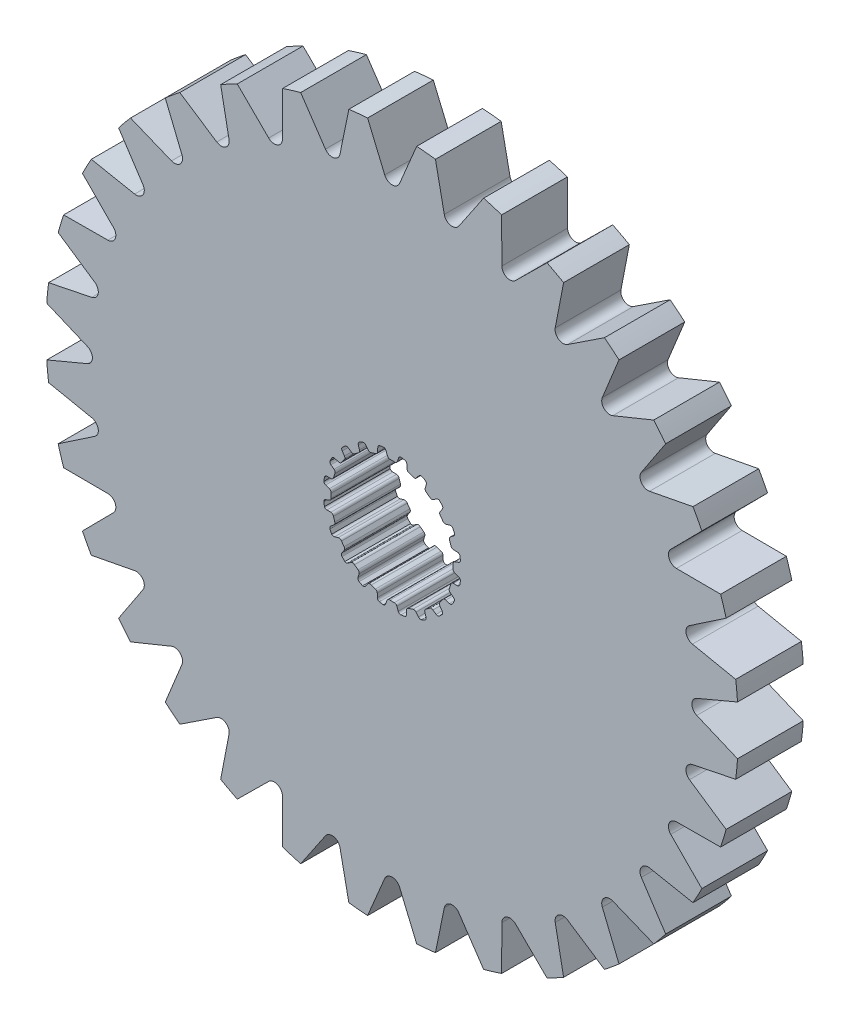
from build123d import *

# Parameters (mm, degrees)
SKETCH1_R           = 16.860601328
BOSS_EXTRUDE1_DEPTH = 1.6002
CUT_EXTRUDE1_DEPTH  = 3.2004


with BuildPart() as part:
    # Sketch1 → Boss-Extrude1 (new body, symmetric)
    with BuildSketch(Plane.XY):
        Circle(SKETCH1_R)
        with BuildLine():
            Line((-0.106949245, 2.969874934), (0.106949245, 2.969874934))
            ThreePointArc((0.106949245, 2.969874934), (0.196343213, 2.986924176), (0.253739238, 3.057547504))
            Line((0.253739238, 3.057547504), (0.315888147, 3.237526941))
            ThreePointArc((0.315888147, 3.237526941), (0.359032156, 3.298322911), (0.4281449, 3.326269005))
            Line((0.4281449, 3.326269005), (0.620027588, 3.2937547))
            ThreePointArc((0.620027588, 3.2937547), (0.689621142, 3.24802576), (0.718272212, 3.169836791))
            Line((0.718272212, 3.169836791), (0.724389167, 2.979527391))
            ThreePointArc((0.724389167, 2.979527391), (0.750934762, 2.9040661), (0.816027049, 2.857568043))
            Line((0.816027049, 2.857568043), (1.019456602, 2.791469774))
            ThreePointArc((1.019456602, 2.791469774), (1.109743823, 2.780060312), (1.186154496, 2.829490741))
            Line((1.186154496, 2.829490741), (1.300878326, 2.981456288))
            ThreePointArc((1.300878326, 2.981456288), (1.360697704, 3.02594446), (1.435063648, 3.031165762))
            Line((1.435063648, 3.031165762), (1.607507455, 2.940947809))
            ThreePointArc((1.607507455, 2.940947809), (1.659563839, 2.875951412), (1.662650905, 2.792735615))
            Line((1.662650905, 2.792735615), (1.609659636, 2.609850378))
            ThreePointArc((1.609659636, 2.609850378), (1.611587176, 2.529879385), (1.659124931, 2.465542482))
            Line((1.659124931, 2.465542482), (1.832172444, 2.339816104))
            ThreePointArc((1.832172444, 2.339816104), (1.914514976, 2.301064775), (2.002460687, 2.32446371))
            Line((2.002460687, 2.32446371), (2.158529469, 2.433539921))
            ThreePointArc((2.158529469, 2.433539921), (2.229168681, 2.457365482), (2.301508367, 2.439350895))
            Line((2.301508367, 2.439350895), (2.437633293, 2.300260456))
            ThreePointArc((2.437633293, 2.300260456), (2.467056864, 2.222358901), (2.444277744, 2.14226202))
            Line((2.444277744, 2.14226202), (2.337365406, 1.984703026))
            ThreePointArc((2.337365406, 1.984703026), (2.314486209, 1.908050449), (2.339816104, 1.832172444))
            Line((2.339816104, 1.832172444), (2.465542482, 1.659124931))
            ThreePointArc((2.465542482, 1.659124931), (2.531880064, 1.596824985), (2.622752074, 1.591901975))
            Line((2.622752074, 1.591901975), (2.804888709, 1.64741171))
            ThreePointArc((2.804888709, 1.64741171), (2.879433095, 1.648242449), (2.942665411, 1.608755366))
            Line((2.942665411, 1.608755366), (3.0291466, 1.434407582))
            ThreePointArc((3.0291466, 1.434407582), (3.033057175, 1.351226417), (2.986641646, 1.282088892))
            Line((2.986641646, 1.282088892), (2.836273564, 1.165279113))
            ThreePointArc((2.836273564, 1.165279113), (2.790827206, 1.099448241), (2.791469774, 1.019456602))
            Line((2.791469774, 1.019456602), (2.857568043, 0.816027049))
            ThreePointArc((2.857568043, 0.816027049), (2.901407091, 0.736276839), (2.986310214, 0.703513784))
            Line((2.986310214, 0.703513784), (3.1766859, 0.700023363))
            ThreePointArc((3.1766859, 0.700023363), (3.247838536, 0.677777961), (3.295773863, 0.620683653))
            Line((3.295773863, 0.620683653), (3.324145932, 0.4281449))
            ThreePointArc((3.324145932, 0.4281449), (3.302160717, 0.347826477), (3.236652255, 0.29641597))
            Line((3.236652255, 0.29641597), (3.057547504, 0.231789562))
            ThreePointArc((3.057547504, 0.231789562), (2.993982591, 0.183224379), (2.969874934, 0.106949245))
            Line((2.969874934, 0.106949245), (2.969874934, -0.106949245))
            ThreePointArc((2.969874934, -0.106949245), (2.986924176, -0.196343213), (3.057547504, -0.253739238))
            Line((3.057547504, -0.253739238), (3.237526941, -0.315888147))
            ThreePointArc((3.237526941, -0.315888147), (3.298322911, -0.359032156), (3.326269005, -0.4281449))
            Line((3.326269005, -0.4281449), (3.2937547, -0.620027588))
            ThreePointArc((3.2937547, -0.620027588), (3.24802576, -0.689621142), (3.169836791, -0.718272212))
            Line((3.169836791, -0.718272212), (2.979527391, -0.724389167))
            ThreePointArc((2.979527391, -0.724389167), (2.9040661, -0.750934762), (2.857568043, -0.816027049))
            Line((2.857568043, -0.816027049), (2.791469774, -1.019456602))
            ThreePointArc((2.791469774, -1.019456602), (2.780060312, -1.109743823), (2.829490741, -1.186154496))
            Line((2.829490741, -1.186154496), (2.981456288, -1.300878326))
            ThreePointArc((2.981456288, -1.300878326), (3.02594446, -1.360697704), (3.031165762, -1.435063648))
            Line((3.031165762, -1.435063648), (2.940947809, -1.607507455))
            ThreePointArc((2.940947809, -1.607507455), (2.875951412, -1.659563839), (2.792735615, -1.662650905))
            Line((2.792735615, -1.662650905), (2.609850378, -1.609659636))
            ThreePointArc((2.609850378, -1.609659636), (2.529879385, -1.611587176), (2.465542482, -1.659124931))
            Line((2.465542482, -1.659124931), (2.339816104, -1.832172444))
            ThreePointArc((2.339816104, -1.832172444), (2.301064775, -1.914514976), (2.32446371, -2.002460687))
            Line((2.32446371, -2.002460687), (2.433539921, -2.158529469))
            ThreePointArc((2.433539921, -2.158529469), (2.457365482, -2.229168681), (2.439350895, -2.301508367))
            Line((2.439350895, -2.301508367), (2.300260456, -2.437633293))
            ThreePointArc((2.300260456, -2.437633293), (2.222358901, -2.467056864), (2.14226202, -2.444277744))
            Line((2.14226202, -2.444277744), (1.984703026, -2.337365406))
            ThreePointArc((1.984703026, -2.337365406), (1.908050449, -2.314486209), (1.832172444, -2.339816104))
            Line((1.832172444, -2.339816104), (1.659124931, -2.465542482))
            ThreePointArc((1.659124931, -2.465542482), (1.596824985, -2.531880064), (1.591901975, -2.622752074))
            Line((1.591901975, -2.622752074), (1.64741171, -2.804888709))
            ThreePointArc((1.64741171, -2.804888709), (1.648242449, -2.879433095), (1.608755366, -2.942665411))
            Line((1.608755366, -2.942665411), (1.434407582, -3.0291466))
            ThreePointArc((1.434407582, -3.0291466), (1.351226417, -3.033057175), (1.282088892, -2.986641646))
            Line((1.282088892, -2.986641646), (1.165279113, -2.836273564))
            ThreePointArc((1.165279113, -2.836273564), (1.099448241, -2.790827206), (1.019456602, -2.791469774))
            Line((1.019456602, -2.791469774), (0.816027049, -2.857568043))
            ThreePointArc((0.816027049, -2.857568043), (0.736276839, -2.901407091), (0.703513784, -2.986310214))
            Line((0.703513784, -2.986310214), (0.700023363, -3.1766859))
            ThreePointArc((0.700023363, -3.1766859), (0.677777961, -3.247838536), (0.620683653, -3.295773863))
            Line((0.620683653, -3.295773863), (0.4281449, -3.324145932))
            ThreePointArc((0.4281449, -3.324145932), (0.347826477, -3.302160717), (0.29641597, -3.236652255))
            Line((0.29641597, -3.236652255), (0.231789562, -3.057547504))
            ThreePointArc((0.231789562, -3.057547504), (0.183224379, -2.993982591), (0.106949245, -2.969874934))
            Line((0.106949245, -2.969874934), (-0.106949245, -2.969874934))
            ThreePointArc((-0.106949245, -2.969874934), (-0.196343213, -2.986924176), (-0.253739238, -3.057547504))
            Line((-0.253739238, -3.057547504), (-0.315888147, -3.237526941))
            ThreePointArc((-0.315888147, -3.237526941), (-0.359032156, -3.298322911), (-0.4281449, -3.326269005))
            Line((-0.4281449, -3.326269005), (-0.620027588, -3.2937547))
            ThreePointArc((-0.620027588, -3.2937547), (-0.689621142, -3.24802576), (-0.718272212, -3.169836791))
            Line((-0.718272212, -3.169836791), (-0.724389167, -2.979527391))
            ThreePointArc((-0.724389167, -2.979527391), (-0.750934762, -2.9040661), (-0.816027049, -2.857568043))
            Line((-0.816027049, -2.857568043), (-1.019456602, -2.791469774))
            ThreePointArc((-1.019456602, -2.791469774), (-1.109743823, -2.780060312), (-1.186154496, -2.829490741))
            Line((-1.186154496, -2.829490741), (-1.300878326, -2.981456288))
            ThreePointArc((-1.300878326, -2.981456288), (-1.360697704, -3.02594446), (-1.435063648, -3.031165762))
            Line((-1.435063648, -3.031165762), (-1.607507455, -2.940947809))
            ThreePointArc((-1.607507455, -2.940947809), (-1.659563839, -2.875951412), (-1.662650905, -2.792735615))
            Line((-1.662650905, -2.792735615), (-1.609659636, -2.609850378))
            ThreePointArc((-1.609659636, -2.609850378), (-1.611587176, -2.529879385), (-1.659124931, -2.465542482))
            Line((-1.659124931, -2.465542482), (-1.832172444, -2.339816104))
            ThreePointArc((-1.832172444, -2.339816104), (-1.914514976, -2.301064775), (-2.002460687, -2.32446371))
            Line((-2.002460687, -2.32446371), (-2.158529469, -2.433539921))
            ThreePointArc((-2.158529469, -2.433539921), (-2.229168681, -2.457365482), (-2.301508367, -2.439350895))
            Line((-2.301508367, -2.439350895), (-2.437633293, -2.300260456))
            ThreePointArc((-2.437633293, -2.300260456), (-2.467056864, -2.222358901), (-2.444277744, -2.14226202))
            Line((-2.444277744, -2.14226202), (-2.337365406, -1.984703026))
            ThreePointArc((-2.337365406, -1.984703026), (-2.314486209, -1.908050449), (-2.339816104, -1.832172444))
            Line((-2.339816104, -1.832172444), (-2.465542482, -1.659124931))
            ThreePointArc((-2.465542482, -1.659124931), (-2.531880064, -1.596824985), (-2.622752074, -1.591901975))
            Line((-2.622752074, -1.591901975), (-2.804888709, -1.64741171))
            ThreePointArc((-2.804888709, -1.64741171), (-2.879433095, -1.648242449), (-2.942665411, -1.608755366))
            Line((-2.942665411, -1.608755366), (-3.0291466, -1.434407582))
            ThreePointArc((-3.0291466, -1.434407582), (-3.033057175, -1.351226417), (-2.986641646, -1.282088892))
            Line((-2.986641646, -1.282088892), (-2.836273564, -1.165279113))
            ThreePointArc((-2.836273564, -1.165279113), (-2.790827206, -1.099448241), (-2.791469774, -1.019456602))
            Line((-2.791469774, -1.019456602), (-2.857568043, -0.816027049))
            ThreePointArc((-2.857568043, -0.816027049), (-2.901407091, -0.736276839), (-2.986310214, -0.703513784))
            Line((-2.986310214, -0.703513784), (-3.1766859, -0.700023363))
            ThreePointArc((-3.1766859, -0.700023363), (-3.247838536, -0.677777961), (-3.295773863, -0.620683653))
            Line((-3.295773863, -0.620683653), (-3.324145932, -0.4281449))
            ThreePointArc((-3.324145932, -0.4281449), (-3.302160717, -0.347826477), (-3.236652255, -0.29641597))
            Line((-3.236652255, -0.29641597), (-3.057547504, -0.231789562))
            ThreePointArc((-3.057547504, -0.231789562), (-2.993982591, -0.183224379), (-2.969874934, -0.106949245))
            Line((-2.969874934, -0.106949245), (-2.969874934, 0.106949245))
            ThreePointArc((-2.969874934, 0.106949245), (-2.986924176, 0.196343213), (-3.057547504, 0.253739238))
            Line((-3.057547504, 0.253739238), (-3.237526941, 0.315888147))
            ThreePointArc((-3.237526941, 0.315888147), (-3.298322911, 0.359032156), (-3.326269005, 0.4281449))
            Line((-3.326269005, 0.4281449), (-3.2937547, 0.620027588))
            ThreePointArc((-3.2937547, 0.620027588), (-3.24802576, 0.689621142), (-3.169836791, 0.718272212))
            Line((-3.169836791, 0.718272212), (-2.979527391, 0.724389167))
            ThreePointArc((-2.979527391, 0.724389167), (-2.9040661, 0.750934762), (-2.857568043, 0.816027049))
            Line((-2.857568043, 0.816027049), (-2.791469774, 1.019456602))
            ThreePointArc((-2.791469774, 1.019456602), (-2.780060312, 1.109743823), (-2.829490741, 1.186154496))
            Line((-2.829490741, 1.186154496), (-2.981456288, 1.300878326))
            ThreePointArc((-2.981456288, 1.300878326), (-3.02594446, 1.360697704), (-3.031165762, 1.435063648))
            Line((-3.031165762, 1.435063648), (-2.940947809, 1.607507455))
            ThreePointArc((-2.940947809, 1.607507455), (-2.875951412, 1.659563839), (-2.792735615, 1.662650905))
            Line((-2.792735615, 1.662650905), (-2.609850378, 1.609659636))
            ThreePointArc((-2.609850378, 1.609659636), (-2.529879385, 1.611587176), (-2.465542482, 1.659124931))
            Line((-2.465542482, 1.659124931), (-2.339816104, 1.832172444))
            ThreePointArc((-2.339816104, 1.832172444), (-2.301064775, 1.914514976), (-2.32446371, 2.002460687))
            Line((-2.32446371, 2.002460687), (-2.433539921, 2.158529469))
            ThreePointArc((-2.433539921, 2.158529469), (-2.457365482, 2.229168681), (-2.439350895, 2.301508367))
            Line((-2.439350895, 2.301508367), (-2.300260456, 2.437633293))
            ThreePointArc((-2.300260456, 2.437633293), (-2.222358901, 2.467056864), (-2.14226202, 2.444277744))
            Line((-2.14226202, 2.444277744), (-1.984703026, 2.337365406))
            ThreePointArc((-1.984703026, 2.337365406), (-1.908050449, 2.314486209), (-1.832172444, 2.339816104))
            Line((-1.832172444, 2.339816104), (-1.659124931, 2.465542482))
            ThreePointArc((-1.659124931, 2.465542482), (-1.596824985, 2.531880064), (-1.591901975, 2.622752074))
            Line((-1.591901975, 2.622752074), (-1.64741171, 2.804888709))
            ThreePointArc((-1.64741171, 2.804888709), (-1.648242449, 2.879433095), (-1.608755366, 2.942665411))
            Line((-1.608755366, 2.942665411), (-1.434407582, 3.0291466))
            ThreePointArc((-1.434407582, 3.0291466), (-1.351226417, 3.033057175), (-1.282088892, 2.986641646))
            Line((-1.282088892, 2.986641646), (-1.165279113, 2.836273564))
            ThreePointArc((-1.165279113, 2.836273564), (-1.099448241, 2.790827206), (-1.019456602, 2.791469774))
            Line((-1.019456602, 2.791469774), (-0.816027049, 2.857568043))
            ThreePointArc((-0.816027049, 2.857568043), (-0.736276839, 2.901407091), (-0.703513784, 2.986310214))
            Line((-0.703513784, 2.986310214), (-0.700023363, 3.1766859))
            ThreePointArc((-0.700023363, 3.1766859), (-0.677777961, 3.247838536), (-0.620683653, 3.295773863))
            Line((-0.620683653, 3.295773863), (-0.4281449, 3.324145932))
            ThreePointArc((-0.4281449, 3.324145932), (-0.347826477, 3.302160717), (-0.29641597, 3.236652255))
            Line((-0.29641597, 3.236652255), (-0.231789562, 3.057547504))
            ThreePointArc((-0.231789562, 3.057547504), (-0.183224379, 2.993982591), (-0.106949245, 2.969874934))
        make_face(mode=Mode.SUBTRACT)
    extrude(amount=BOSS_EXTRUDE1_DEPTH, both=True)

    # Sketch2 → Cut-Extrude1 (cut)
    with BuildSketch(Plane.XY.offset(1.6002)):
        with BuildLine():
            Line((-1.195753421, 16.818146476), (-0.361266579, 14.83454632))
            ThreePointArc((-0.361266579, 14.83454632), (0, 14.594594775), (0.361266579, 14.83454632))
            Line((0.361266579, 14.83454632), (1.195753421, 16.818146476))
            ThreePointArc((1.195753421, 16.818146476), (0, 16.860601328), (-1.195753421, 16.818146476))
        make_face()
        with BuildLine():
            Line((4.453834966, 16.261710587), (3.248401362, 14.479025059))
            ThreePointArc((3.248401362, 14.479025059), (2.847264194, 14.314163729), (2.539751475, 14.619984285))
            Line((2.539751475, 14.619984285), (2.108280258, 16.728270427))
            ThreePointArc((2.108280258, 16.728270427), (3.289340142, 16.536629601), (4.453834966, 16.261710587))
        make_face()
        with BuildLine():
            Line((7.540758131, 15.080346281), (6.010701902, 13.567082984))
            ThreePointArc((6.010701902, 13.567082984), (5.585109623, 13.483647398), (5.343168305, 13.843584454))
            Line((5.343168305, 13.843584454), (5.331293908, 15.995536327))
            ThreePointArc((5.331293908, 15.995536327), (6.452272788, 15.577164472), (7.540758131, 15.080346281))
        make_face()
        with BuildLine():
            Line((10.33789419, 13.319452723), (8.542014538, 12.133765519))
            ThreePointArc((8.542014538, 12.133765519), (8.10832242, 12.134962059), (7.941250173, 12.535183435))
            Line((7.941250173, 12.535183435), (8.349428924, 14.648102736))
            ThreePointArc((8.349428924, 14.648102736), (9.367248208, 14.019077649), (10.33789419, 13.319452723))
        make_face()
        with BuildLine():
            Line((12.737750772, 11.046700068), (10.745062347, 10.23415425))
            ThreePointArc((10.745062347, 10.23415425), (10.319936934, 10.319936934), (10.23415425, 10.745062347))
            Line((10.23415425, 10.745062347), (11.046700068, 12.737750772))
            ThreePointArc((11.046700068, 12.737750772), (11.922245534, 11.922245534), (12.737750772, 11.046700068))
        make_face()
        with BuildLine():
            Line((14.648102736, 8.349428924), (12.535183435, 7.941250173))
            ThreePointArc((12.535183435, 7.941250173), (12.134962059, 8.10832242), (12.133765519, 8.542014538))
            Line((12.133765519, 8.542014538), (13.319452723, 10.33789419))
            ThreePointArc((13.319452723, 10.33789419), (14.019077649, 9.367248208), (14.648102736, 8.349428924))
        make_face()
        with BuildLine():
            Line((15.995536327, 5.331293908), (13.843584454, 5.343168305))
            ThreePointArc((13.843584454, 5.343168305), (13.483647398, 5.585109623), (13.567082984, 6.010701902))
            Line((13.567082984, 6.010701902), (15.080346281, 7.540758131))
            ThreePointArc((15.080346281, 7.540758131), (15.577164472, 6.452272788), (15.995536327, 5.331293908))
        make_face()
        with BuildLine():
            Line((16.728270427, 2.108280258), (14.619984285, 2.539751475))
            ThreePointArc((14.619984285, 2.539751475), (14.314163729, 2.847264194), (14.479025059, 3.248401362))
            Line((14.479025059, 3.248401362), (16.261710587, 4.453834966))
            ThreePointArc((16.261710587, 4.453834966), (16.536629601, 3.289340142), (16.728270427, 2.108280258))
        make_face()
        with BuildLine():
            Line((16.818146476, -1.195753421), (14.83454632, -0.361266579))
            ThreePointArc((14.83454632, -0.361266579), (14.594594775, 0), (14.83454632, 0.361266579))
            Line((14.83454632, 0.361266579), (16.818146476, 1.195753421))
            ThreePointArc((16.818146476, 1.195753421), (16.860601328, 0), (16.818146476, -1.195753421))
        make_face()
        with BuildLine():
            Line((16.261710587, -4.453834966), (14.479025059, -3.248401362))
            ThreePointArc((14.479025059, -3.248401362), (14.314163729, -2.847264194), (14.619984285, -2.539751475))
            Line((14.619984285, -2.539751475), (16.728270427, -2.108280258))
            ThreePointArc((16.728270427, -2.108280258), (16.536629601, -3.289340142), (16.261710587, -4.453834966))
        make_face()
        with BuildLine():
            Line((15.080346281, -7.540758131), (13.567082984, -6.010701902))
            ThreePointArc((13.567082984, -6.010701902), (13.483647398, -5.585109623), (13.843584454, -5.343168305))
            Line((13.843584454, -5.343168305), (15.995536327, -5.331293908))
            ThreePointArc((15.995536327, -5.331293908), (15.577164472, -6.452272788), (15.080346281, -7.540758131))
        make_face()
        with BuildLine():
            Line((13.319452723, -10.33789419), (12.133765519, -8.542014538))
            ThreePointArc((12.133765519, -8.542014538), (12.134962059, -8.10832242), (12.535183435, -7.941250173))
            Line((12.535183435, -7.941250173), (14.648102736, -8.349428924))
            ThreePointArc((14.648102736, -8.349428924), (14.019077649, -9.367248208), (13.319452723, -10.33789419))
        make_face()
        with BuildLine():
            Line((11.046700068, -12.737750772), (10.23415425, -10.745062347))
            ThreePointArc((10.23415425, -10.745062347), (10.319936934, -10.319936934), (10.745062347, -10.23415425))
            Line((10.745062347, -10.23415425), (12.737750772, -11.046700068))
            ThreePointArc((12.737750772, -11.046700068), (11.922245534, -11.922245534), (11.046700068, -12.737750772))
        make_face()
        with BuildLine():
            Line((8.349428924, -14.648102736), (7.941250173, -12.535183435))
            ThreePointArc((7.941250173, -12.535183435), (8.10832242, -12.134962059), (8.542014538, -12.133765519))
            Line((8.542014538, -12.133765519), (10.33789419, -13.319452723))
            ThreePointArc((10.33789419, -13.319452723), (9.367248208, -14.019077649), (8.349428924, -14.648102736))
        make_face()
        with BuildLine():
            Line((5.331293908, -15.995536327), (5.343168305, -13.843584454))
            ThreePointArc((5.343168305, -13.843584454), (5.585109623, -13.483647398), (6.010701902, -13.567082984))
            Line((6.010701902, -13.567082984), (7.540758131, -15.080346281))
            ThreePointArc((7.540758131, -15.080346281), (6.452272788, -15.577164472), (5.331293908, -15.995536327))
        make_face()
        with BuildLine():
            Line((2.108280258, -16.728270427), (2.539751475, -14.619984285))
            ThreePointArc((2.539751475, -14.619984285), (2.847264194, -14.314163729), (3.248401362, -14.479025059))
            Line((3.248401362, -14.479025059), (4.453834966, -16.261710587))
            ThreePointArc((4.453834966, -16.261710587), (3.289340142, -16.536629601), (2.108280258, -16.728270427))
        make_face()
        with BuildLine():
            Line((-1.195753421, -16.818146476), (-0.361266579, -14.83454632))
            ThreePointArc((-0.361266579, -14.83454632), (0, -14.594594775), (0.361266579, -14.83454632))
            Line((0.361266579, -14.83454632), (1.195753421, -16.818146476))
            ThreePointArc((1.195753421, -16.818146476), (0, -16.860601328), (-1.195753421, -16.818146476))
        make_face()
        with BuildLine():
            Line((-4.453834966, -16.261710587), (-3.248401362, -14.479025059))
            ThreePointArc((-3.248401362, -14.479025059), (-2.847264194, -14.314163729), (-2.539751475, -14.619984285))
            Line((-2.539751475, -14.619984285), (-2.108280258, -16.728270427))
            ThreePointArc((-2.108280258, -16.728270427), (-3.289340142, -16.536629601), (-4.453834966, -16.261710587))
        make_face()
        with BuildLine():
            Line((-7.540758131, -15.080346281), (-6.010701902, -13.567082984))
            ThreePointArc((-6.010701902, -13.567082984), (-5.585109623, -13.483647398), (-5.343168305, -13.843584454))
            Line((-5.343168305, -13.843584454), (-5.331293908, -15.995536327))
            ThreePointArc((-5.331293908, -15.995536327), (-6.452272788, -15.577164472), (-7.540758131, -15.080346281))
        make_face()
        with BuildLine():
            Line((-10.33789419, -13.319452723), (-8.542014538, -12.133765519))
            ThreePointArc((-8.542014538, -12.133765519), (-8.10832242, -12.134962059), (-7.941250173, -12.535183435))
            Line((-7.941250173, -12.535183435), (-8.349428924, -14.648102736))
            ThreePointArc((-8.349428924, -14.648102736), (-9.367248208, -14.019077649), (-10.33789419, -13.319452723))
        make_face()
        with BuildLine():
            Line((-12.737750772, -11.046700068), (-10.745062347, -10.23415425))
            ThreePointArc((-10.745062347, -10.23415425), (-10.319936934, -10.319936934), (-10.23415425, -10.745062347))
            Line((-10.23415425, -10.745062347), (-11.046700068, -12.737750772))
            ThreePointArc((-11.046700068, -12.737750772), (-11.922245534, -11.922245534), (-12.737750772, -11.046700068))
        make_face()
        with BuildLine():
            Line((-14.648102736, -8.349428924), (-12.535183435, -7.941250173))
            ThreePointArc((-12.535183435, -7.941250173), (-12.134962059, -8.10832242), (-12.133765519, -8.542014538))
            Line((-12.133765519, -8.542014538), (-13.319452723, -10.33789419))
            ThreePointArc((-13.319452723, -10.33789419), (-14.019077649, -9.367248208), (-14.648102736, -8.349428924))
        make_face()
        with BuildLine():
            Line((-15.995536327, -5.331293908), (-13.843584454, -5.343168305))
            ThreePointArc((-13.843584454, -5.343168305), (-13.483647398, -5.585109623), (-13.567082984, -6.010701902))
            Line((-13.567082984, -6.010701902), (-15.080346281, -7.540758131))
            ThreePointArc((-15.080346281, -7.540758131), (-15.577164472, -6.452272788), (-15.995536327, -5.331293908))
        make_face()
        with BuildLine():
            Line((-16.728270427, -2.108280258), (-14.619984285, -2.539751475))
            ThreePointArc((-14.619984285, -2.539751475), (-14.314163729, -2.847264194), (-14.479025059, -3.248401362))
            Line((-14.479025059, -3.248401362), (-16.261710587, -4.453834966))
            ThreePointArc((-16.261710587, -4.453834966), (-16.536629601, -3.289340142), (-16.728270427, -2.108280258))
        make_face()
        with BuildLine():
            Line((-16.818146476, 1.195753421), (-14.83454632, 0.361266579))
            ThreePointArc((-14.83454632, 0.361266579), (-14.594594775, 0), (-14.83454632, -0.361266579))
            Line((-14.83454632, -0.361266579), (-16.818146476, -1.195753421))
            ThreePointArc((-16.818146476, -1.195753421), (-16.860601328, 0), (-16.818146476, 1.195753421))
        make_face()
        with BuildLine():
            Line((-16.261710587, 4.453834966), (-14.479025059, 3.248401362))
            ThreePointArc((-14.479025059, 3.248401362), (-14.314163729, 2.847264194), (-14.619984285, 2.539751475))
            Line((-14.619984285, 2.539751475), (-16.728270427, 2.108280258))
            ThreePointArc((-16.728270427, 2.108280258), (-16.536629601, 3.289340142), (-16.261710587, 4.453834966))
        make_face()
        with BuildLine():
            Line((-15.080346281, 7.540758131), (-13.567082984, 6.010701902))
            ThreePointArc((-13.567082984, 6.010701902), (-13.483647398, 5.585109623), (-13.843584454, 5.343168305))
            Line((-13.843584454, 5.343168305), (-15.995536327, 5.331293908))
            ThreePointArc((-15.995536327, 5.331293908), (-15.577164472, 6.452272788), (-15.080346281, 7.540758131))
        make_face()
        with BuildLine():
            Line((-13.319452723, 10.33789419), (-12.133765519, 8.542014538))
            ThreePointArc((-12.133765519, 8.542014538), (-12.134962059, 8.10832242), (-12.535183435, 7.941250173))
            Line((-12.535183435, 7.941250173), (-14.648102736, 8.349428924))
            ThreePointArc((-14.648102736, 8.349428924), (-14.019077649, 9.367248208), (-13.319452723, 10.33789419))
        make_face()
        with BuildLine():
            Line((-11.046700068, 12.737750772), (-10.23415425, 10.745062347))
            ThreePointArc((-10.23415425, 10.745062347), (-10.319936934, 10.319936934), (-10.745062347, 10.23415425))
            Line((-10.745062347, 10.23415425), (-12.737750772, 11.046700068))
            ThreePointArc((-12.737750772, 11.046700068), (-11.922245534, 11.922245534), (-11.046700068, 12.737750772))
        make_face()
        with BuildLine():
            Line((-8.349428924, 14.648102736), (-7.941250173, 12.535183435))
            ThreePointArc((-7.941250173, 12.535183435), (-8.10832242, 12.134962059), (-8.542014538, 12.133765519))
            Line((-8.542014538, 12.133765519), (-10.33789419, 13.319452723))
            ThreePointArc((-10.33789419, 13.319452723), (-9.367248208, 14.019077649), (-8.349428924, 14.648102736))
        make_face()
        with BuildLine():
            Line((-5.331293908, 15.995536327), (-5.343168305, 13.843584454))
            ThreePointArc((-5.343168305, 13.843584454), (-5.585109623, 13.483647398), (-6.010701902, 13.567082984))
            Line((-6.010701902, 13.567082984), (-7.540758131, 15.080346281))
            ThreePointArc((-7.540758131, 15.080346281), (-6.452272788, 15.577164472), (-5.331293908, 15.995536327))
        make_face()
        with BuildLine():
            Line((-2.108280258, 16.728270427), (-2.539751475, 14.619984285))
            ThreePointArc((-2.539751475, 14.619984285), (-2.847264194, 14.314163729), (-3.248401362, 14.479025059))
            Line((-3.248401362, 14.479025059), (-4.453834966, 16.261710587))
            ThreePointArc((-4.453834966, 16.261710587), (-3.289340142, 16.536629601), (-2.108280258, 16.728270427))
        make_face()
    extrude(amount=-CUT_EXTRUDE1_DEPTH, mode=Mode.SUBTRACT)


solid = part.part
